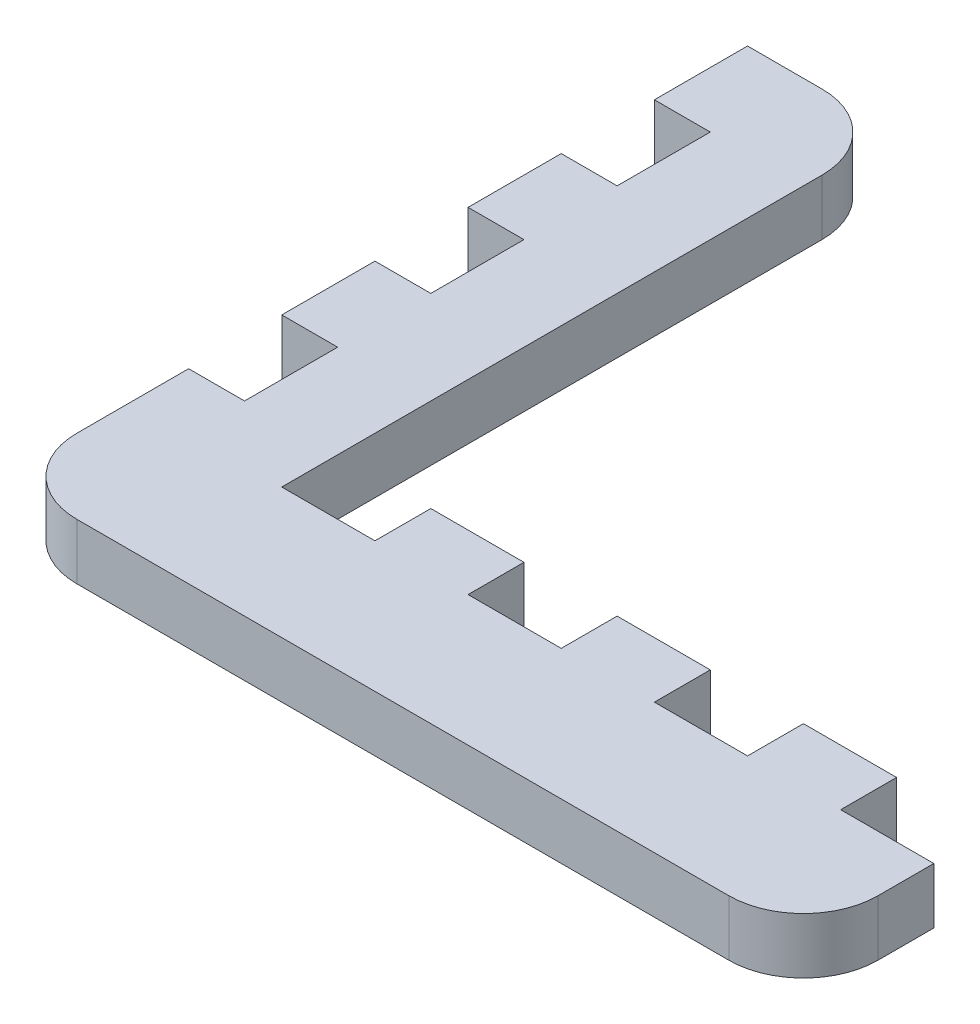
from build123d import *

# Parameters (mm, degrees)
SKETCH1_W           = 46
SKETCH1_H           = 40
BOSS_EXTRUDE1_DEPTH = 3
SKETCH3_W           = 35
SKETCH3_H           = 30
CUT_EXTRUDE1_DEPTH  = 3
SKETCH4_W           = 5
SKETCH4_H           = 3
CUT_EXTRUDE3_DEPTH  = 3
SKETCH6_W           = 7
SKETCH6_H           = 3
BOSS_EXTRUDE2_DEPTH = 5
SKETCH7_W           = 11
SKETCH7_H           = 40
CUT_EXTRUDE4_DEPTH  = 3
SKETCH8_W           = 5
SKETCH8_H           = 3
BOSS_EXTRUDE3_DEPTH = 30
SKETCH9_W           = 5
SKETCH9_H           = 3
SKETCH9_W_2         = 10
BOSS_EXTRUDE4_DEPTH = 3
FILLET2_R           = 4


with BuildPart() as part:
    # Sketch1 → Boss-Extrude1 (new body)
    with BuildSketch(Plane(origin=(0, 0, 0), x_dir=(1, 0, 0), z_dir=(0, 1, 0))):
        Rectangle(SKETCH1_W, SKETCH1_H)
    extrude(amount=BOSS_EXTRUDE1_DEPTH)

    # Sketch3 → Cut-Extrude1 (cut)
    with BuildSketch(Plane(origin=(0, 3, 0), x_dir=(1, 0, 0), z_dir=(0, 1, 0))):
        with Locations((5.5, 5)):
            Rectangle(SKETCH3_W, SKETCH3_H)
    extrude(amount=-CUT_EXTRUDE1_DEPTH, mode=Mode.SUBTRACT)

    # Sketch4 → Cut-Extrude3 (cut)
    with BuildSketch(Plane(origin=(0, 0, 10), x_dir=(-1, 0, 0), z_dir=(0, 0, -1))):
        with Locations((-15.5, 1.5)):
            Rectangle(SKETCH4_W, SKETCH4_H)
        with Locations((-5.5, 1.5)):
            Rectangle(SKETCH4_W, SKETCH4_H)
        with Locations((4.5, 1.5)):
            Rectangle(SKETCH4_W, SKETCH4_H)
    extrude(amount=-CUT_EXTRUDE3_DEPTH, mode=Mode.SUBTRACT)

    # Sketch6 → Boss-Extrude2 (add)
    with BuildSketch(Plane(origin=(23, 0, 0), x_dir=(0, 0, -1), z_dir=(1, 0, 0))):
        with Locations((-16.5, 1.5)):
            Rectangle(SKETCH6_W, SKETCH6_H)
    extrude(amount=BOSS_EXTRUDE2_DEPTH)

    # Sketch7 → Cut-Extrude4 (cut)
    with BuildSketch(Plane.XZ):
        with Locations((-17.5, 0)):
            Rectangle(SKETCH7_W, SKETCH7_H)
    extrude(amount=-CUT_EXTRUDE4_DEPTH, mode=Mode.SUBTRACT)

    # Sketch8 → Boss-Extrude3 (add)
    with BuildSketch(Plane(origin=(0, 0, 10), x_dir=(-1, 0, 0), z_dir=(0, 0, -1))):
        with Locations((9.5, 1.5)):
            Rectangle(SKETCH8_W, SKETCH8_H)
    extrude(amount=BOSS_EXTRUDE3_DEPTH)

    # Sketch9 → Boss-Extrude4 (add)
    with BuildSketch(Plane.ZY.offset(12)):
        with Locations((-17.5, 1.5)):
            Rectangle(SKETCH9_W, SKETCH9_H)
        with Locations((-7.5, 1.5)):
            Rectangle(SKETCH9_W, SKETCH9_H)
        with Locations((2.5, 1.5)):
            Rectangle(SKETCH9_W, SKETCH9_H)
        with Locations((15, 1.5)):
            Rectangle(SKETCH9_W_2, SKETCH9_H)
    extrude(amount=BOSS_EXTRUDE4_DEPTH)

    # Fillet2
    fillet2_edges = [part.edges().sort_by_distance(p)[0] for p in [
        (-7, 1.5, -20),
        (-15, 1.5, 20),
        (28, 1.5, 20),
    ]]
    fillet(fillet2_edges, radius=FILLET2_R)


solid = part.part
